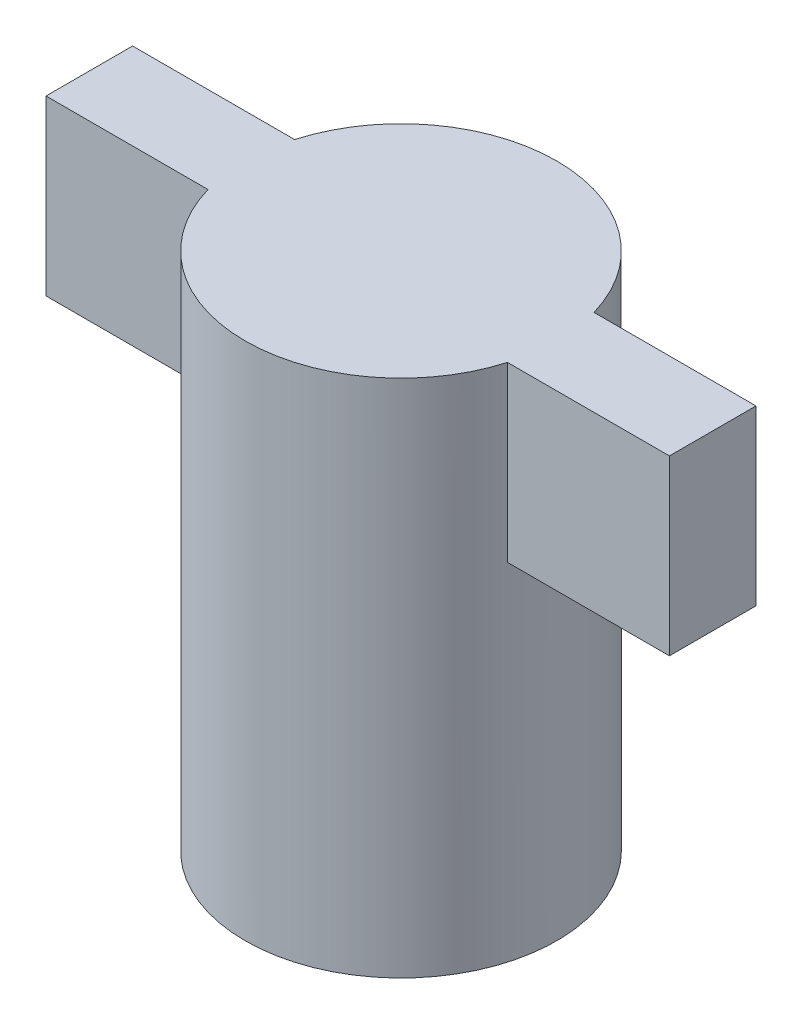
from build123d import *

# Parameters (mm, degrees)
SKETCH2_R           = 4.5
BOSS_EXTRUDE1_DEPTH = 15
SKETCH4_R           = 4
CUT_EXTRUDE2_DEPTH  = 1.5
SKETCH5_R           = 3
CUT_EXTRUDE3_DEPTH  = 2.5
CUT_EXTRUDE4_DEPTH  = 6
SKETCH7_W           = 18
SKETCH7_H           = 2.5
BOSS_EXTRUDE2_DEPTH = 5


with BuildPart() as part:
    # Sketch2 → Boss-Extrude1 (new body)
    with BuildSketch(Plane(origin=(0, 0, 0), x_dir=(1, 0, 0), z_dir=(0, 1, 0))):
        Circle(SKETCH2_R)
    extrude(amount=BOSS_EXTRUDE1_DEPTH)

    # Sketch4 → Cut-Extrude2 (cut)
    with BuildSketch(Plane.XZ):
        with Locations((0, 0.009200476)):
            Circle(SKETCH4_R)
    extrude(amount=-CUT_EXTRUDE2_DEPTH, mode=Mode.SUBTRACT)

    # Sketch5 → Cut-Extrude3 (cut)
    with BuildSketch(Plane.XZ.offset(-1.5)):
        with Locations((0.006133651, -0.009200476)):
            Circle(SKETCH5_R)
    extrude(amount=-CUT_EXTRUDE3_DEPTH, mode=Mode.SUBTRACT)

    # Sketch6 → Cut-Extrude4 (cut)
    with BuildSketch(Plane.XZ.offset(-4)):
        with BuildLine():
            Line((-2.446188527, -1.739471433), (2.441510318, -1.739471433))
            ThreePointArc((2.441510318, -1.739471433), (2.997660896, 0.000528567), (2.441510318, 1.740528567))
            Line((2.441510318, 1.740528567), (-2.446188527, 1.740528567))
            ThreePointArc((-2.446188527, 1.740528567), (-3.002339104, 0.000528567), (-2.446188527, -1.739471433))
        make_face()
    extrude(amount=-CUT_EXTRUDE4_DEPTH, mode=Mode.SUBTRACT)

    # Sketch7 → Boss-Extrude2 (add)
    with BuildSketch(Plane(origin=(0, 15, 0), x_dir=(1, 0, 0), z_dir=(0, 1, 0))):
        Rectangle(SKETCH7_W, SKETCH7_H)
    extrude(amount=-BOSS_EXTRUDE2_DEPTH)


solid = part.part
